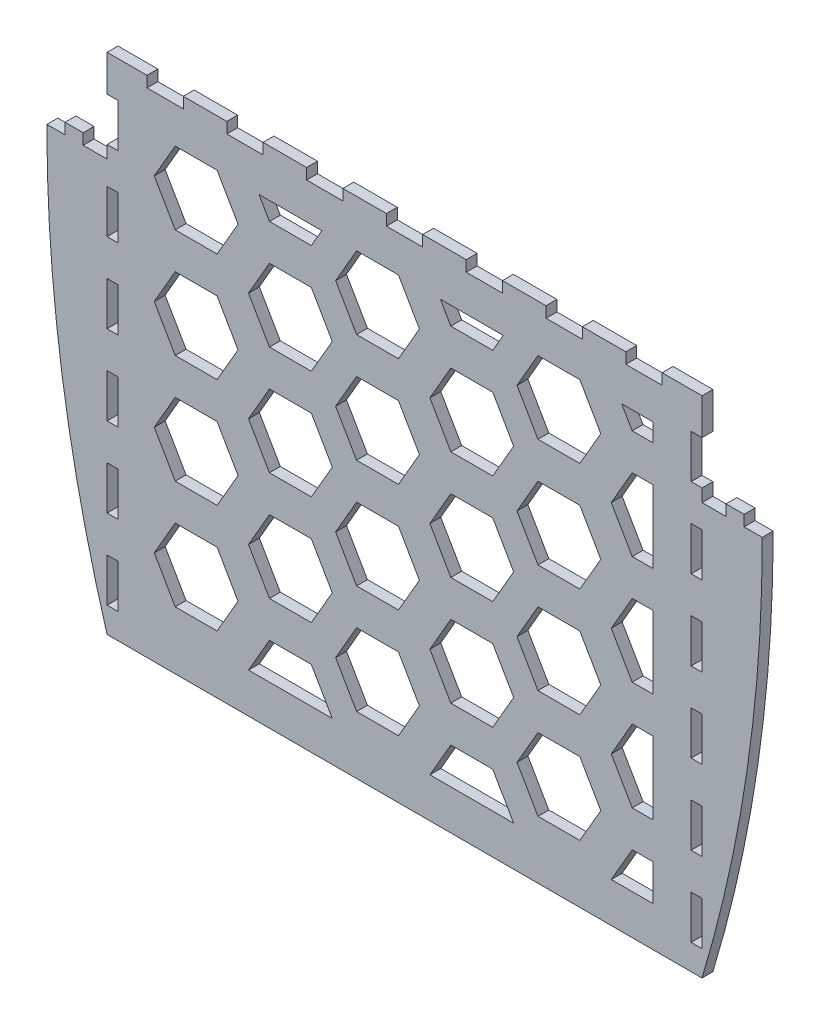
from build123d import *

# Parameters (mm, degrees)
BOSS_EXTRUDE1_DEPTH = 3
SKETCH2_W           = 10
SKETCH2_H           = 3
SKETCH2_W_2         = 3
SKETCH2_H_2         = 12
CUT_EXTRUDE1_DEPTH  = 10
CUT_EXTRUDE2_DEPTH  = 4


with BuildPart() as part:
    # Sketch1 → Boss-Extrude1 (new body)
    with BuildSketch(Plane.XY.offset(152)):
        with BuildLine():
            Line((-82, 69.5), (82, 69.5))
            Line((82, 69.5), (82, 44))
            Line((82, 44), (88.6, 44))
            Line((88.6, 44), (88.6, 47))
            Line((88.6, 47), (93.6, 47))
            Line((93.6, 47), (93.6, 44))
            Line((93.6, 44), (98.6, 44))
            Line((98.6, 44), (98.6, 43.377104502))
            ThreePointArc((98.6, 43.377104502), (94.427800977, -13.668492876), (82, -69.5))
            Line((82, -69.5), (-82, -69.5))
            ThreePointArc((-82, -69.5), (-94.427800977, -13.668492876), (-98.6, 43.377104502))
            Line((-98.6, 43.377104502), (-98.6, 44))
            Line((-98.6, 44), (-93.6, 44))
            Line((-93.6, 44), (-93.6, 47))
            Line((-93.6, 47), (-88.6, 47))
            Line((-88.6, 47), (-88.6, 44))
            Line((-88.6, 44), (-82, 44))
            Line((-82, 44), (-82, 69.5))
        make_face()
    extrude(amount=BOSS_EXTRUDE1_DEPTH)

    # Sketch2 → Cut-Extrude1 (cut)
    with BuildSketch(Plane.XY.offset(155)):
        with Locations((22, 68)):
            Rectangle(SKETCH2_W, SKETCH2_H)
        with Locations((0, 68)):
            Rectangle(SKETCH2_W, SKETCH2_H)
        with Locations((44, 68)):
            Rectangle(SKETCH2_W, SKETCH2_H)
        with Locations((-22, 68)):
            Rectangle(SKETCH2_W, SKETCH2_H)
        with Locations((66, 68)):
            Rectangle(SKETCH2_W, SKETCH2_H)
        with Locations((-44, 68)):
            Rectangle(SKETCH2_W, SKETCH2_H)
        with Locations((80.5, 53.5)):
            Rectangle(SKETCH2_W_2, SKETCH2_H_2)
        with Locations((-66, 68)):
            Rectangle(SKETCH2_W, SKETCH2_H)
        with Locations((-80.5, 53.5)):
            Rectangle(SKETCH2_W_2, SKETCH2_H_2)
        with Locations((-80.5, 31.5)):
            Rectangle(SKETCH2_W_2, SKETCH2_H_2)
        with Locations((-80.5, 9.5)):
            Rectangle(SKETCH2_W_2, SKETCH2_H_2)
        with Locations((-80.5, -12.5)):
            Rectangle(SKETCH2_W_2, SKETCH2_H_2)
        with Locations((-80.5, -34.5)):
            Rectangle(SKETCH2_W_2, SKETCH2_H_2)
        with Locations((-80.5, -56.5)):
            Rectangle(SKETCH2_W_2, SKETCH2_H_2)
        with Locations((80.5, -56.5)):
            Rectangle(SKETCH2_W_2, SKETCH2_H_2)
        with Locations((80.5, -34.5)):
            Rectangle(SKETCH2_W_2, SKETCH2_H_2)
        with Locations((80.5, -12.5)):
            Rectangle(SKETCH2_W_2, SKETCH2_H_2)
        with Locations((80.5, 9.5)):
            Rectangle(SKETCH2_W_2, SKETCH2_H_2)
        with Locations((80.5, 31.5)):
            Rectangle(SKETCH2_W_2, SKETCH2_H_2)
    extrude(amount=-CUT_EXTRUDE1_DEPTH, mode=Mode.SUBTRACT)

    # Sketch3 → Cut-Extrude2 (cut, through all)
    with BuildSketch(Plane.XY.offset(155)):
        Polygon((-45.905989232, 46.5), (-51.679491924, 56.5), (-63.226497308, 56.5), (-69, 46.5), (-63.226497308, 36.5), (-51.679491924, 36.5), align=None)
        Polygon((-19.925227119, 31.5), (-25.698729811, 41.5), (-37.245735195, 41.5), (-43.019237886, 31.5), (-37.245735195, 21.5), (-25.698729811, 21.5), align=None)
        Polygon((4.094010768, 46.5), (-1.679491924, 56.5), (-13.226497308, 56.5), (-19, 46.5), (-13.226497308, 36.5), (-1.679491924, 36.5), align=None)
        Polygon((30.074772881, 31.5), (24.301270189, 41.5), (12.754264805, 41.5), (6.980762114, 31.5), (12.754264805, 21.5), (24.301270189, 21.5), align=None)
        Polygon((54.094010768, 46.5), (48.320508076, 56.5), (36.773502692, 56.5), (31, 46.5), (36.773502692, 36.5), (48.320508076, 36.5), align=None)
        Polygon((68.527767497, 41.5), (62.754264805, 41.5), (56.980762114, 31.5), (62.754264805, 21.5), (68.527767497, 21.5), align=None)
        Polygon((4.094010768, 16.5), (-1.679491924, 26.5), (-13.226497308, 26.5), (-19, 16.5), (-13.226497308, 6.5), (-1.679491924, 6.5), align=None)
        Polygon((30.074772881, 1.5), (24.301270189, 11.5), (12.754264805, 11.5), (6.980762114, 1.5), (12.754264805, -8.5), (24.301270189, -8.5), align=None)
        Polygon((54.094010768, 16.5), (48.320508076, 26.5), (36.773502692, 26.5), (31, 16.5), (36.773502692, 6.5), (48.320508076, 6.5), align=None)
        Polygon((68.527767497, 11.5), (62.754264805, 11.5), (56.980762114, 1.5), (62.754264805, -8.5), (68.527767497, -8.5), align=None)
        Polygon((4.094010768, -13.5), (-1.679491924, -3.5), (-13.226497308, -3.5), (-19, -13.5), (-13.226497308, -23.5), (-1.679491924, -23.5), align=None)
        Polygon((30.074772881, -28.5), (24.301270189, -18.5), (12.754264805, -18.5), (6.980762114, -28.5), (12.754264805, -38.5), (24.301270189, -38.5), align=None)
        Polygon((54.094010768, -13.5), (48.320508076, -3.5), (36.773502692, -3.5), (31, -13.5), (36.773502692, -23.5), (48.320508076, -23.5), align=None)
        Polygon((68.527767497, -18.5), (62.754264805, -18.5), (56.980762114, -28.5), (62.754264805, -38.5), (68.527767497, -38.5), align=None)
        Polygon((4.094010768, -43.5), (-1.679491924, -33.5), (-13.226497308, -33.5), (-19, -43.5), (-13.226497308, -53.5), (-1.679491924, -53.5), align=None)
        Polygon((30.074772881, -58.5), (24.301270189, -48.5), (12.754264805, -48.5), (6.980762114, -58.5), align=None)
        Polygon((54.094010768, -43.5), (48.320508076, -33.5), (36.773502692, -33.5), (31, -43.5), (36.773502692, -53.5), (48.320508076, -53.5), align=None)
        Polygon((68.527767497, -48.5), (62.754264805, -48.5), (56.980762114, -58.5), (68.527767497, -58.5), align=None)
        Polygon((-45.905989232, 16.5), (-51.679491924, 26.5), (-63.226497308, 26.5), (-69, 16.5), (-63.226497308, 6.5), (-51.679491924, 6.5), align=None)
        Polygon((-19.925227119, 1.5), (-25.698729811, 11.5), (-37.245735195, 11.5), (-43.019237886, 1.5), (-37.245735195, -8.5), (-25.698729811, -8.5), align=None)
        Polygon((-45.905989232, -13.5), (-51.679491924, -3.5), (-63.226497308, -3.5), (-69, -13.5), (-63.226497308, -23.5), (-51.679491924, -23.5), align=None)
        Polygon((-19.925227119, -28.5), (-25.698729811, -18.5), (-37.245735195, -18.5), (-43.019237886, -28.5), (-37.245735195, -38.5), (-25.698729811, -38.5), align=None)
        Polygon((-45.905989232, -43.5), (-51.679491924, -33.5), (-63.226497308, -33.5), (-69, -43.5), (-63.226497308, -53.5), (-51.679491924, -53.5), align=None)
        Polygon((-19.925227119, -58.5), (-25.698729811, -48.5), (-37.245735195, -48.5), (-43.019237886, -58.5), align=None)
        Polygon((-40.132486541, 56.5), (-37.245735195, 51.5), (-25.698729811, 51.5), (-22.811978465, 56.5), align=None)
        Polygon((24.301270189, 51.5), (27.188021535, 56.5), (9.867513459, 56.5), (12.754264805, 51.5), align=None)
        Polygon((59.867513459, 56.5), (68.527767497, 56.5), (68.527767497, 51.5), (62.754264805, 51.5), align=None)
    extrude(amount=-CUT_EXTRUDE2_DEPTH, mode=Mode.SUBTRACT)


solid = part.part
